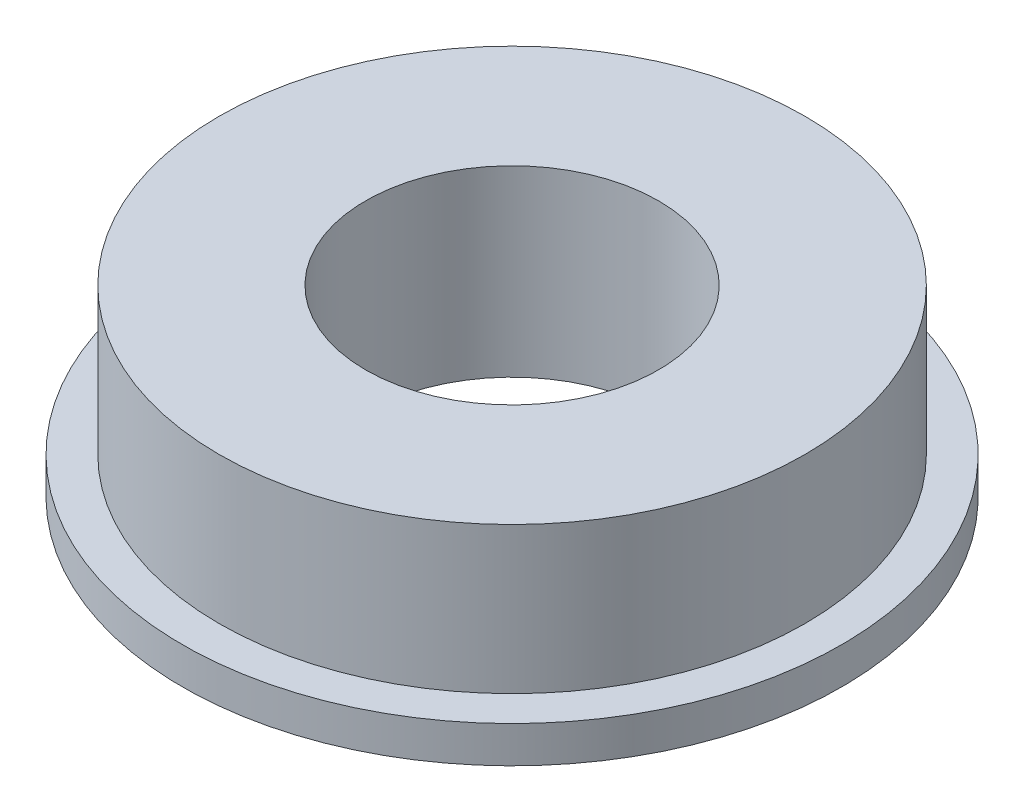
from build123d import *


with BuildPart() as part:
    # Sketch1 → Revolve1 (revolve)
    with BuildSketch(Plane.XY):
        Polygon((-9, -1.5), (-9, -2.5), (-4, -2.5), (-4, 2.5), (-8, 2.5), (-8, -1.5), align=None)
    revolve(axis=Axis((0, -2.5, 0), (0, 1, 0)))


solid = part.part
